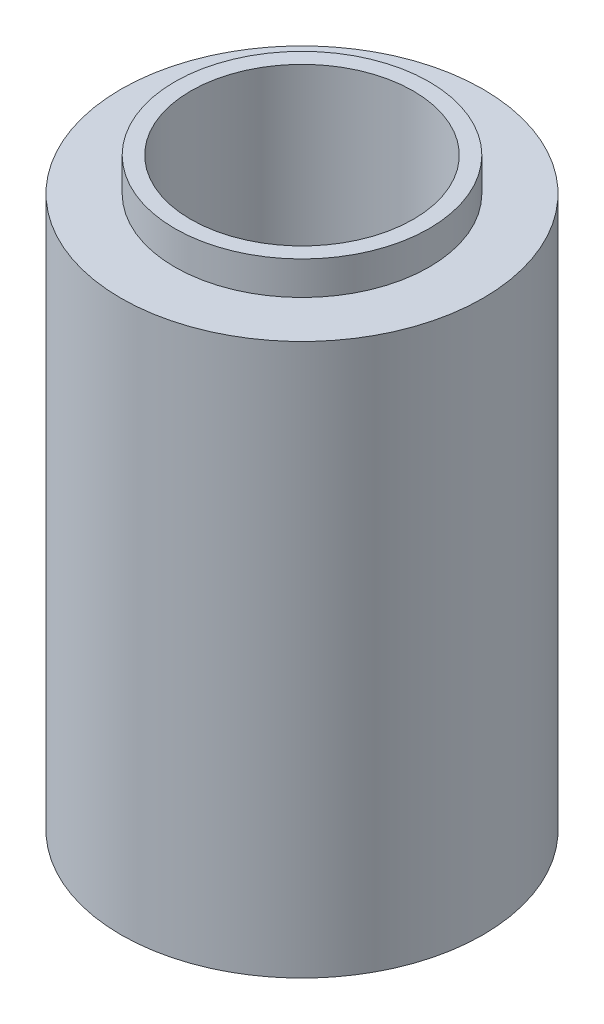
from build123d import *

# Parameters (mm, degrees)
SKETCH1_R           = 17.9
BOSS_EXTRUDE1_DEPTH = 54.51
SKETCH2_R           = 12.5735
BOSS_EXTRUDE2_DEPTH = 3.3
SKETCH4_R           = 11
CUT_EXTRUDE2_DEPTH  = 59.3


with BuildPart() as part:
    # Sketch1 → Boss-Extrude1 (new body)
    with BuildSketch(Plane(origin=(0, 0, 0), x_dir=(1, 0, 0), z_dir=(0, 1, 0))):
        Circle(SKETCH1_R)
    extrude(amount=BOSS_EXTRUDE1_DEPTH)

    # Sketch2 → Boss-Extrude2 (add)
    with BuildSketch(Plane(origin=(0, 54.51, 0), x_dir=(1, 0, 0), z_dir=(0, 1, 0))):
        Circle(SKETCH2_R)
    extrude(amount=BOSS_EXTRUDE2_DEPTH)

    # Sketch4 → Cut-Extrude2 (cut)
    with BuildSketch(Plane.XZ):
        Circle(SKETCH4_R)
    extrude(amount=-CUT_EXTRUDE2_DEPTH, mode=Mode.SUBTRACT)


solid = part.part
